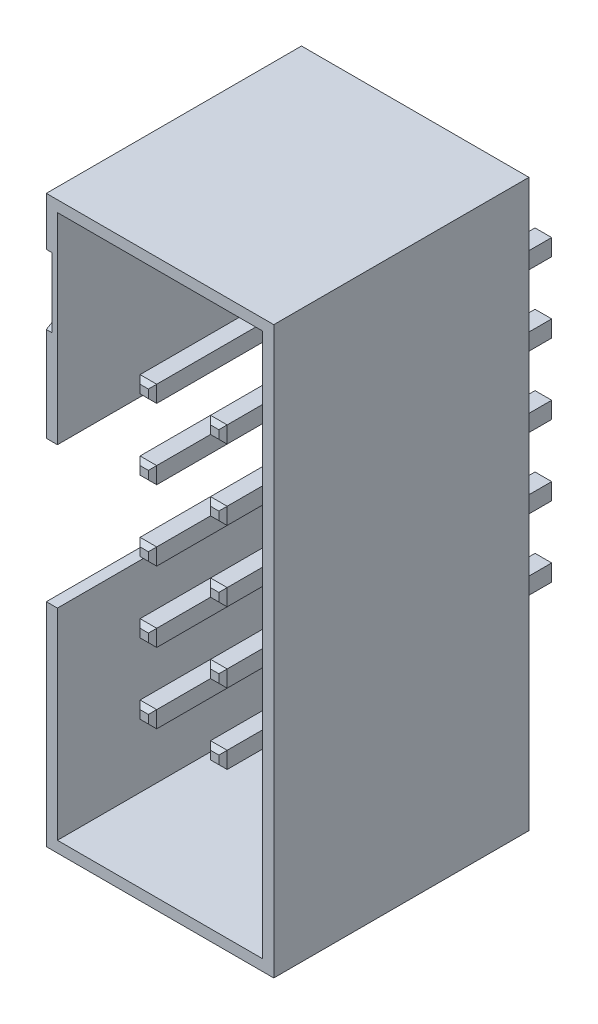
from build123d import *

# Parameters (mm, degrees)
ESQUISSE1_W             = 8.2
ESQUISSE1_H             = 20.4
BOSS_EXTRU_1_DEPTH      = 9.2
ESQUISSE2_W             = 7.4
ESQUISSE2_H             = 19.6
ENL_V_MAT_EXTRU_1_DEPTH = 8
ESQUISSE3_W             = 0.6
ESQUISSE3_H             = 0.6
BOSS_EXTRU_2_DEPTH      = 3.5
BOSS_EXTRU_2_DEPTH_BACK = 8.5
CHANFREIN1_SIZE         = 0.15
ESQUISSE4_W             = 0.4
ESQUISSE4_H             = 5.1
ENL_V_MAT_EXTRU_2_DEPTH = 8
ENL_V_MAT_EXTRU_3_DEPTH = 0.2


with BuildPart() as part:
    # Esquisse1 → Boss.-Extru.1 (new body)
    with BuildSketch(Plane.XY):
        with Locations((4.1, 10.2)):
            Rectangle(ESQUISSE1_W, ESQUISSE1_H)
    extrude(amount=BOSS_EXTRU_1_DEPTH)

    # Esquisse2 → Enlèv. mat.-Extru.1 (cut)
    with BuildSketch(Plane.XY.offset(9.2)):
        with Locations((4.1, 10.2)):
            Rectangle(ESQUISSE2_W, ESQUISSE2_H)
    extrude(amount=-ENL_V_MAT_EXTRU_1_DEPTH, mode=Mode.SUBTRACT)

    # Esquisse3 → Boss.-Extru.2 (add, two sides)
    with BuildSketch(Plane(origin=(0, 0, 0), x_dir=(-1, 0, 0), z_dir=(0, 0, -1))) as boss_extru_2_sk:
        with Locations((-5.37, 15.28)):
            Rectangle(ESQUISSE3_W, ESQUISSE3_H)
        with Locations((-2.83, 15.28)):
            Rectangle(ESQUISSE3_W, ESQUISSE3_H)
        with Locations((-5.37, 12.74)):
            Rectangle(ESQUISSE3_W, ESQUISSE3_H)
        with Locations((-2.83, 12.74)):
            Rectangle(ESQUISSE3_W, ESQUISSE3_H)
        with Locations((-5.37, 10.2)):
            Rectangle(ESQUISSE3_W, ESQUISSE3_H)
        with Locations((-2.83, 10.2)):
            Rectangle(ESQUISSE3_W, ESQUISSE3_H)
        with Locations((-5.37, 7.66)):
            Rectangle(ESQUISSE3_W, ESQUISSE3_H)
        with Locations((-2.83, 7.66)):
            Rectangle(ESQUISSE3_W, ESQUISSE3_H)
        with Locations((-5.37, 5.12)):
            Rectangle(ESQUISSE3_W, ESQUISSE3_H)
        with Locations((-2.83, 5.12)):
            Rectangle(ESQUISSE3_W, ESQUISSE3_H)
    extrude(amount=BOSS_EXTRU_2_DEPTH)
    extrude(boss_extru_2_sk.sketch, amount=-BOSS_EXTRU_2_DEPTH_BACK)

    # Chanfrein1
    chanfrein1_edges = [part.edges().sort_by_distance(p)[0] for p in [
        (5.07, 10.2, 8.5),
        (5.37, 9.9, 8.5),
        (5.67, 10.2, 8.5),
        (5.37, 10.5, 8.5),
        (5.07, 10.2, -3.5),
        (5.37, 10.5, -3.5),
        (5.67, 10.2, -3.5),
        (5.37, 9.9, -3.5),
        (2.53, 10.2, 8.5),
        (2.83, 9.9, 8.5),
        (3.13, 10.2, 8.5),
        (2.83, 10.5, 8.5),
        (2.53, 10.2, -3.5),
        (2.83, 10.5, -3.5),
        (3.13, 10.2, -3.5),
        (2.83, 9.9, -3.5),
        (5.07, 7.66, 8.5),
        (5.37, 7.36, 8.5),
        (5.67, 7.66, 8.5),
        (5.37, 7.96, 8.5),
        (5.07, 7.66, -3.5),
        (5.37, 7.96, -3.5),
        (5.67, 7.66, -3.5),
        (5.37, 7.36, -3.5),
        (2.53, 7.66, 8.5),
        (2.83, 7.36, 8.5),
        (3.13, 7.66, 8.5),
        (2.83, 7.96, 8.5),
        (2.53, 7.66, -3.5),
        (2.83, 7.96, -3.5),
        (3.13, 7.66, -3.5),
        (2.83, 7.36, -3.5),
        (5.07, 5.12, 8.5),
        (5.37, 4.82, 8.5),
        (5.67, 5.12, 8.5),
        (5.37, 5.42, 8.5),
        (5.07, 5.12, -3.5),
        (5.37, 5.42, -3.5),
        (5.67, 5.12, -3.5),
        (5.37, 4.82, -3.5),
        (2.53, 5.12, 8.5),
        (2.83, 4.82, 8.5),
        (3.13, 5.12, 8.5),
        (2.83, 5.42, 8.5),
        (2.53, 5.12, -3.5),
        (2.83, 5.42, -3.5),
        (3.13, 5.12, -3.5),
        (2.83, 4.82, -3.5),
        (5.07, 15.28, 8.5),
        (5.37, 14.98, 8.5),
        (5.67, 15.28, 8.5),
        (5.37, 15.58, 8.5),
        (5.07, 15.28, -3.5),
        (5.37, 15.58, -3.5),
        (5.67, 15.28, -3.5),
        (5.37, 14.98, -3.5),
        (2.53, 15.28, 8.5),
        (2.83, 14.98, 8.5),
        (3.13, 15.28, 8.5),
        (2.83, 15.58, 8.5),
        (2.53, 15.28, -3.5),
        (2.83, 15.58, -3.5),
        (3.13, 15.28, -3.5),
        (2.83, 14.98, -3.5),
        (5.07, 12.74, 8.5),
        (5.37, 12.44, 8.5),
        (5.67, 12.74, 8.5),
        (5.37, 13.04, 8.5),
        (5.07, 12.74, -3.5),
        (5.37, 13.04, -3.5),
        (5.67, 12.74, -3.5),
        (5.37, 12.44, -3.5),
        (2.53, 12.74, 8.5),
        (2.83, 12.44, 8.5),
        (3.13, 12.74, 8.5),
        (2.83, 13.04, 8.5),
        (2.53, 12.74, -3.5),
        (2.83, 13.04, -3.5),
        (3.13, 12.74, -3.5),
        (2.83, 12.44, -3.5),
    ]]
    chamfer(chanfrein1_edges, length=CHANFREIN1_SIZE)

    # Esquisse4 → Enlèv. mat.-Extru.2 (cut)
    with BuildSketch(Plane.XY.offset(9.2)):
        with Locations((0.2, 10.2)):
            Rectangle(ESQUISSE4_W, ESQUISSE4_H)
    extrude(amount=-ENL_V_MAT_EXTRU_2_DEPTH, mode=Mode.SUBTRACT)

    # Esquisse5 → Enlèv. mat.-Extru.3 (cut)
    with BuildSketch(Plane.ZY):
        Polygon((9.2, 18.65), (9.2, 16.15), (7.034936491, 17.4), align=None)
    extrude(amount=-ENL_V_MAT_EXTRU_3_DEPTH, mode=Mode.SUBTRACT)


solid = part.part
